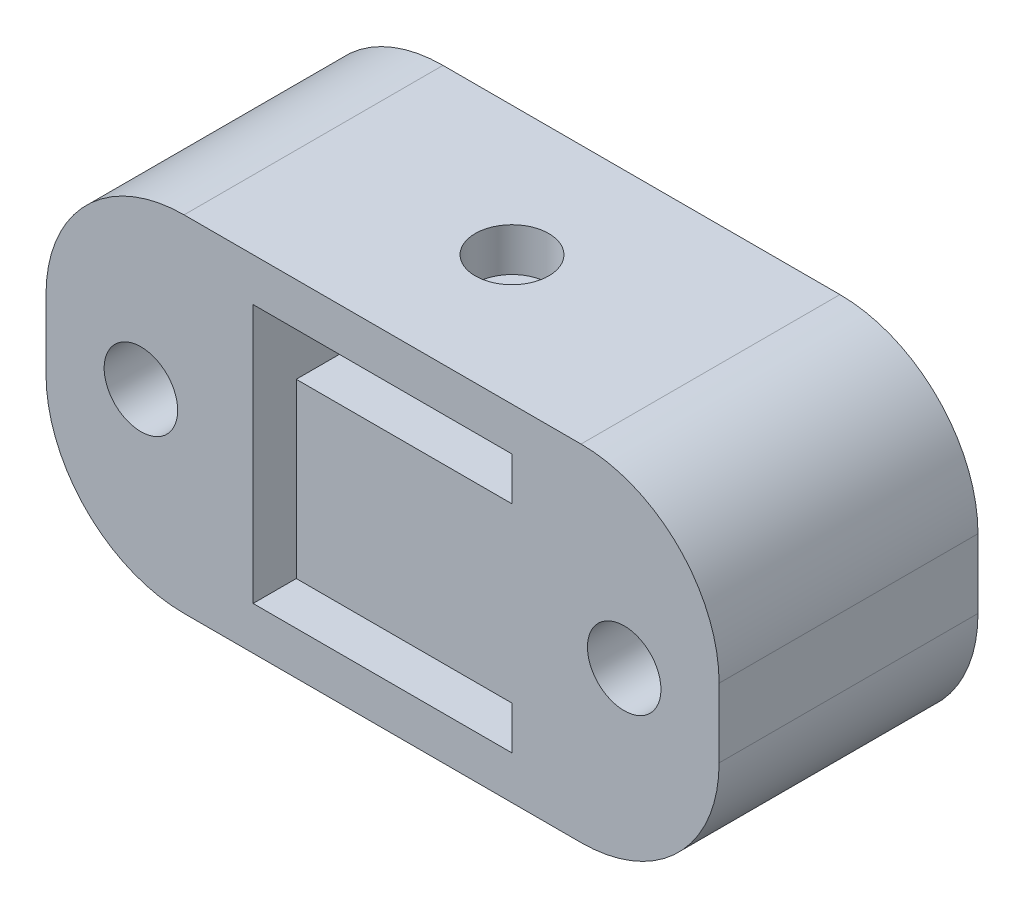
from build123d import *

# Parameters (mm, degrees)
SKETCH1_W                 = 24.765
SKETCH1_H                 = 12.7
BOSS_EXTRUDE1_DEPTH       = 9.525
CUT_EXTRUDE1_DEPTH        = 10.525
FILLET1_R                 = 5.08
F_6_32_TAPPED_HOLE2_D     = 2.7051
F_6_32_TAPPED_HOLE1_D     = 2.7051
F_6_32_TAPPED_HOLE1_DEPTH = 11.176


with BuildPart() as part:
    # Sketch1 → Boss-Extrude1 (new body)
    with BuildSketch(Plane.XY):
        Rectangle(SKETCH1_W, SKETCH1_H)
    extrude(amount=BOSS_EXTRUDE1_DEPTH)

    # Sketch2 → Cut-Extrude1 (cut, through all)
    with BuildSketch(Plane.XY.offset(9.525)):
        Polygon((4.7625, 4.7625), (-4.7625, 4.7625), (-4.7625, -4.7625), (4.7625, -4.7625), (4.7625, -3.175), (-3.175, -3.175), (-3.175, 3.175), (4.7625, 3.175), align=None)
    extrude(amount=-CUT_EXTRUDE1_DEPTH, mode=Mode.SUBTRACT)

    # Fillet1
    fillet1_edges = [part.edges().sort_by_distance(p)[0] for p in [
        (-12.3825, 6.35, 4.7625),
        (12.3825, 6.35, 4.7625),
        (12.3825, -6.35, 4.7625),
        (-12.3825, -6.35, 4.7625),
    ]]
    fillet(fillet1_edges, radius=FILLET1_R)

    # #6-32 Tapped Hole2 (through all)
    with Locations(Plane.XY.offset(9.525)):
        with Locations((-8.89, 0), (8.89, 0)):
            Hole(F_6_32_TAPPED_HOLE2_D / 2)

    # #6-32 Tapped Hole1
    with Locations(Plane(origin=(0, 6.35, 0), x_dir=(1, 0, 0), z_dir=(0, 1, 0))):
        with Locations((0, -4.7625)):
            Hole(F_6_32_TAPPED_HOLE1_D / 2, depth=F_6_32_TAPPED_HOLE1_DEPTH)


solid = part.part
